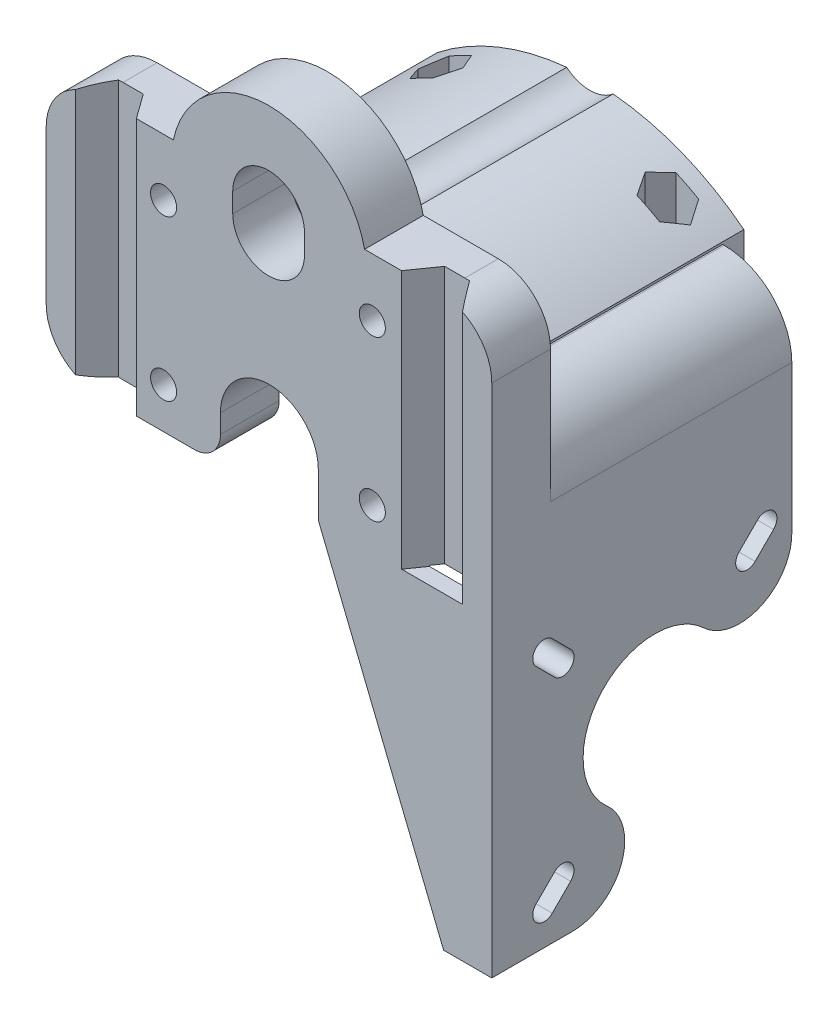
from build123d import *

# Parameters (mm, degrees)
SKETCH1_R               = 2
BOSS_EXTRUDE1_DEPTH     = 9
BOSS_EXTRUDE2_DEPTH     = 40.25
CUT_EXTRUDE1_DEPTH      = 50
SKETCH6_W               = 3.25
SKETCH6_H               = 24.113806611
CUT_EXTRUDE2_DEPTH      = 10.6
SKETCH7_R               = 1.8
CUT_EXTRUDE3_DEPTH      = 39.5
CUT_EXTRUDE3_DEPTH_BACK = 39.5
CUT_EXTRUDE4_DEPTH      = 20.85
SKETCH9_R               = 4.05
CUT_EXTRUDE5_DEPTH      = 2.4
CUT_EXTRUDE6_DEPTH      = 6.5


with BuildPart() as part:
    # Sketch1 → Boss-Extrude1 (new body)
    with BuildSketch(Plane.XY):
        with BuildLine():
            Line((0, 0), (-7.3836, 0))
            Line((-7.3836, 0), (-26.6, 47.5))
            Line((-26.6, 47.5), (-26.6, 54.25))
            ThreePointArc((-26.6, 54.25), (-34.1, 61.75), (-41.6, 54.25))
            Line((-41.6, 54.25), (-41.6, 51.364872675))
            ThreePointArc((-41.6, 51.364872675), (-42.771572875, 48.53644555), (-45.6, 47.364872675))
            Line((-45.6, 47.364872675), (-60.316706428, 47.364872675))
            ThreePointArc((-60.316706428, 47.364872675), (-65.973560677, 49.708018426), (-68.316706428, 55.364872675))
            Line((-68.316706428, 55.364872675), (-68.316706428, 78.864872675))
            ThreePointArc((-68.316706428, 78.864872675), (-65.973560677, 84.521726925), (-60.316706428, 86.864872675))
            Line((-60.316706428, 86.864872675), (-48.816706428, 86.864872675))
            ThreePointArc((-48.816706428, 86.864872675), (-34.212822301, 98.749840665), (-19.5, 87))
            Line((-19.5, 87), (-8, 87))
            ThreePointArc((-8, 87), (-2.343145751, 84.656854249), (0, 79))
            Line((0, 79), (0, 0))
        make_face()
        with Locations((-50.316706428, 78.114872675)):
            Circle(SKETCH1_R, mode=Mode.SUBTRACT)
        with Locations((-18.316706428, 78.114872675)):
            Circle(SKETCH1_R, mode=Mode.SUBTRACT)
        with Locations((-50.316706428, 53.614872675)):
            Circle(SKETCH1_R, mode=Mode.SUBTRACT)
        with Locations((-18.316706428, 53.614872675)):
            Circle(SKETCH1_R, mode=Mode.SUBTRACT)
    extrude(amount=BOSS_EXTRUDE1_DEPTH)

    # Sketch3 → Boss-Extrude2 (add)
    with BuildSketch(Plane(origin=(0, 0, 0), x_dir=(-1, 0, 0), z_dir=(0, 0, -1))):
        with BuildLine():
            Line((0, 0), (5.4, 0))
            Line((5.4, 0), (5.4, 58.675))
            ThreePointArc((5.4, 58.675), (6.886433085, 62.263566915), (10.475, 63.75))
            Line((10.475, 63.75), (57.6, 63.75))
            Line((57.6, 63.75), (57.6, 69.45))
            ThreePointArc((57.6, 69.45), (34.1, 77.587816557), (10.6, 69.45))
            Line((10.6, 69.45), (10.6, 69.1))
            Line((10.6, 69.1), (10.375, 69.1))
            ThreePointArc((10.375, 69.1), (3.038767145, 66.061232855), (0, 58.725))
            Line((0, 58.725), (0, 0))
        make_face()
    extrude(amount=BOSS_EXTRUDE2_DEPTH)

    # Sketch5 → Cut-Extrude1 (cut)
    with BuildSketch(Plane.XY.offset(9)):
        with BuildLine():
            Line((-28.716706428, 84.614872675), (-28.716706428, 81.614872675))
            ThreePointArc((-28.716706428, 81.614872675), (-34.216706428, 76.114872675), (-39.716706428, 81.614872675))
            Line((-39.716706428, 81.614872675), (-39.716706428, 84.614872675))
            ThreePointArc((-39.716706428, 84.614872675), (-34.216706428, 90.114872675), (-28.716706428, 84.614872675))
        make_face()
    extrude(amount=-CUT_EXTRUDE1_DEPTH, mode=Mode.SUBTRACT)

    # Sketch6 → Cut-Extrude2 (cut)
    with BuildSketch(Plane(origin=(0, 0, 0), x_dir=(0, 0, -1), z_dir=(1, 0, 0))):
        with BuildLine():
            Line((37, 58.725), (37, 36.056406461))
            ThreePointArc((37, 36.056406461), (32.178877657, 28.715102977), (23.526315789, 30.222130056))
            ThreePointArc((23.526315789, 30.222130056), (7.877678535, 29.618078863), (8.691491696, 13.978947368))
            ThreePointArc((8.691491696, 13.978947368), (10.853899034, 5.156725387), (3.37621293, 0))
            Line((3.37621293, 0), (37.9285464, 0))
            Line((37.9285464, 0), (40.25, 0))
            Line((40.25, 0), (40.25, 58.725))
            Line((40.25, 58.725), (37, 58.725))
        make_face()
        with BuildLine():
            Line((3.096104185, 37.603623706), (0.26725, 40.431623706))
            ThreePointArc((0.26725, 40.431623706), (-2.207623706, 40.43125), (-2.20725, 37.956376294))
            Line((-2.20725, 37.956376294), (0.621604185, 35.128376294))
            ThreePointArc((0.621604185, 35.128376294), (3.096477891, 35.12875), (3.096104185, 37.603623706))
        make_face()
        with BuildLine():
            ThreePointArc((31.73275, 40.431623706), (34.207623706, 40.43125), (34.20725, 37.956376294))
            Line((34.20725, 37.956376294), (31.378395815, 35.128376294))
            ThreePointArc((31.378395815, 35.128376294), (28.903522109, 35.12875), (28.903895815, 37.603623706))
            Line((28.903895815, 37.603623706), (31.73275, 40.431623706))
        make_face()
        with BuildLine():
            ThreePointArc((0.26725, 3.968376294), (-2.207623706, 3.96875), (-2.20725, 6.443623706))
            Line((-2.20725, 6.443623706), (0.621604185, 9.271623706))
            ThreePointArc((0.621604185, 9.271623706), (3.096477891, 9.27125), (3.096104185, 6.796376294))
            Line((3.096104185, 6.796376294), (0.26725, 3.968376294))
        make_face()
        with Locations((38.625, 70.781903306)):
            Rectangle(SKETCH6_W, SKETCH6_H)
    extrude(amount=-CUT_EXTRUDE2_DEPTH, mode=Mode.SUBTRACT)

    # Sketch7 → Cut-Extrude3 (cut, two sides)
    with BuildSketch(Plane(origin=(0, 86.864872675, 0), x_dir=(1, 0, 0), z_dir=(0, 1, 0))) as cut_extrude3_sk:
        with Locations((-51.6, 34.75)):
            Circle(SKETCH7_R)
        with Locations((-51.6, 6)):
            Circle(SKETCH7_R)
        with Locations((-16.745188355, 6.033054654)):
            Circle(SKETCH7_R)
        with Locations((-16.799718585, 34.78300294)):
            Circle(SKETCH7_R)
        Polygon((-13.833, -9), (-11.1, -5.12), (-7.3, -5.12), (-4.5, -9), align=None)
        Polygon((-63.816706428, -9), (-61.016706428, -5.217), (-57.216706428, -5.217), (-54.486706428, -9), align=None)
    extrude(amount=CUT_EXTRUDE3_DEPTH, mode=Mode.SUBTRACT)
    extrude(cut_extrude3_sk.sketch, amount=-CUT_EXTRUDE3_DEPTH_BACK, mode=Mode.SUBTRACT)

    # Sketch8 → Cut-Extrude4 (cut)
    with BuildSketch(Plane(origin=(0, 86.864872675, 0), x_dir=(1, 0, 0), z_dir=(0, 1, 0))):
        Polygon((-48.135898385, 34.75), (-49.867949192, 37.75), (-53.332050808, 37.75), (-55.064101615, 34.75), (-53.332050808, 31.75), (-49.867949192, 31.75), align=None)
        Polygon((-48.135898385, 6), (-49.867949192, 9), (-53.332050808, 9), (-55.064101615, 6), (-53.332050808, 3), (-49.867949192, 3), align=None)
        Polygon((-18.469686835, 9.036434754), (-15.005594549, 9.044474276), (-13.266585975, 6.048502117), (-14.991669687, 3.044490435), (-18.455761973, 3.036450912), (-20.194770547, 6.032423072), align=None)
        Polygon((-18.522485268, 31.786373486), (-20.261493842, 34.782345646), (-18.53641013, 37.786357328), (-15.072317844, 37.79439685), (-13.33330927, 34.798424691), (-15.058392982, 31.794413009), align=None)
    extrude(amount=-CUT_EXTRUDE4_DEPTH, mode=Mode.SUBTRACT)

    # Sketch9 → Cut-Extrude5 (cut)
    with BuildSketch(Plane(origin=(0, 0, 0), x_dir=(-1, 0, 0), z_dir=(0, 0, -1))):
        with Locations((18.316706428, 78.114872675)):
            Circle(SKETCH9_R)
        with Locations((50.316706428, 78.114872675)):
            Circle(SKETCH9_R)
        with Locations((18.316706428, 53.614872675)):
            Circle(SKETCH9_R)
        with Locations((50.316706428, 53.614872675)):
            Circle(SKETCH9_R)
    extrude(amount=-CUT_EXTRUDE5_DEPTH, mode=Mode.SUBTRACT)

    # Sketch10 → Cut-Extrude6 (cut)
    with BuildSketch(Plane(origin=(0, 0, 0), x_dir=(-1, 0, 0), z_dir=(0, 0, -1))):
        Polygon((26.6, 47.5), (5.4, 47.5), (5.4, 0), (7.3836, 0), align=None)
    extrude(amount=-CUT_EXTRUDE6_DEPTH, mode=Mode.SUBTRACT)


solid = part.part
